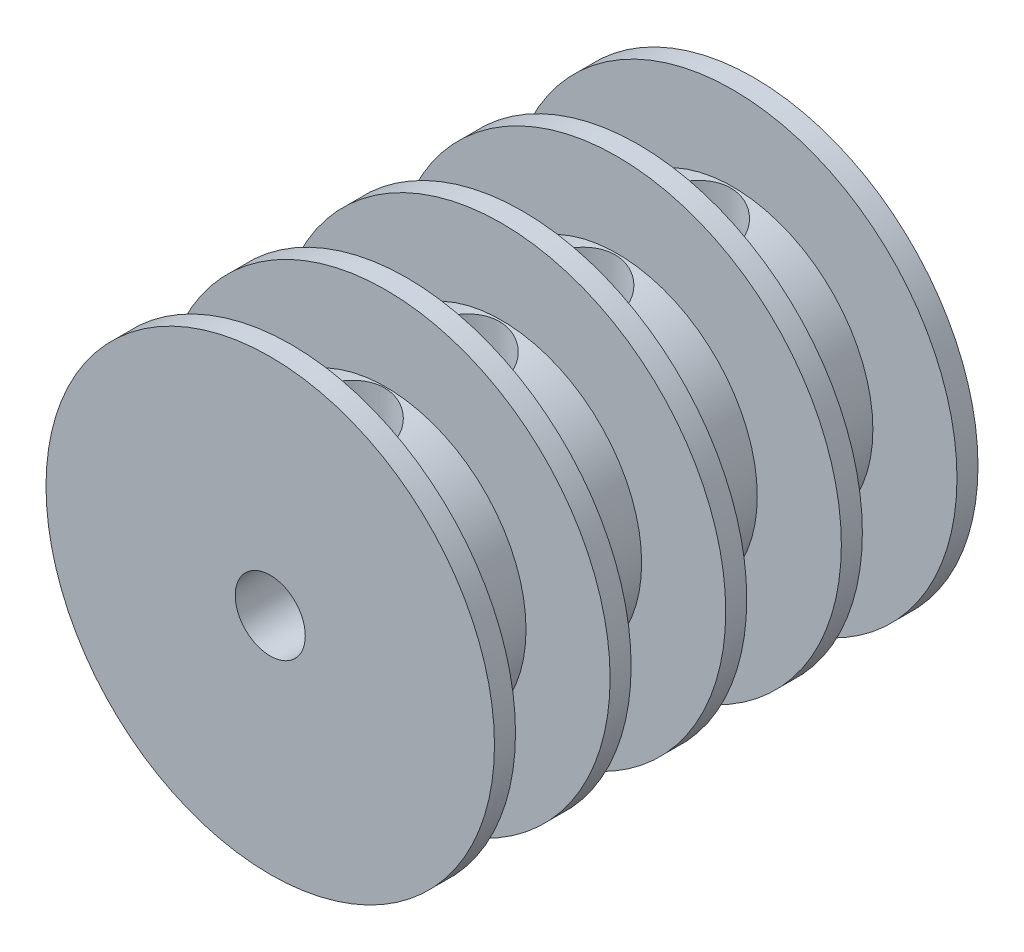
from build123d import *

# Parameters (mm, degrees)
SKETCH_1_R               = 16
EXTRUDE_1_DEPTH          = 1.5
SKETCH_2_R               = 10
EXTRUDE_2_DEPTH          = 15
SKETCH_3_R               = 16
EXTRUDE_3_DEPTH          = 1.5
SKETCH_4_R               = 2.5
CUT_EXTRUDE_1_DEPTH      = 19
SKETCH_11_R              = 16
SKETCH_11_R_2            = 10
EXTRUDE_4_DEPTH          = 0.75
HOLE_WIZARD_M3_2_D       = 2.5
PATTERN_CIRCULAR_2_COUNT = 2
HOLE_WIZARD_M3_3_D       = 2.5
SKETCH_21_R              = 10
EXTRUDE_7_DEPTH          = 15
SKETCH_22_R              = 16
EXTRUDE_8_DEPTH          = 1.5
SKETCH_23_R              = 16
EXTRUDE_9_DEPTH          = 0.75
PATTERN_LINEAR_1_COUNT   = 3
PATTERN_LINEAR_1_PITCH   = 8.25
PATTERN_CIRCULAR_1_COUNT = 2
HOLE_WIZARD_M3_4_D       = 2.5
SKETCH_26_R              = 2.5
CUT_EXTRUDE_2_DEPTH      = 35.5


with BuildPart() as part:
    # 스케치1 → 보스-돌출1 (new body)
    with BuildSketch(Plane.XY):
        Circle(SKETCH_1_R)
    extrude(amount=EXTRUDE_1_DEPTH)

    # 스케치2 → 보스-돌출2 (add)
    with BuildSketch(Plane.XY.offset(1.5)):
        Circle(SKETCH_2_R)
    extrude(amount=EXTRUDE_2_DEPTH)

    # 스케치3 → 보스-돌출3 (add)
    with BuildSketch(Plane.XY.offset(16.5)):
        Circle(SKETCH_3_R)
    extrude(amount=EXTRUDE_3_DEPTH)

    # 스케치4 → 컷-돌출1 (cut, through all)
    with BuildSketch(Plane(origin=(0, 25, 0), x_dir=(-1, 0, 0), z_dir=(0, 0, 1))):
        with Locations((0, 25)):
            Circle(SKETCH_4_R)
    extrude(amount=CUT_EXTRUDE_1_DEPTH, mode=Mode.SUBTRACT)

    # 스케치11 → 보스-돌출4 (add, symmetric)
    with BuildSketch(Plane(origin=(0, 0, 9), x_dir=(-1, 0, 0), z_dir=(0, 0, -1))):
        Circle(SKETCH_11_R)
        Circle(SKETCH_11_R_2, mode=Mode.SUBTRACT)
    extrude(amount=EXTRUDE_4_DEPTH, both=True)

    # 스케치10 → Ø6.5 (6.5) 지름 구멍2 (revolve, cut)
    with BuildSketch(Plane(origin=(0, 16, 4.9), x_dir=(0, 0, 1), z_dir=(1, 0, 0))):
        Polygon((0, 0), (0, 11.452797012), (3.25, 9.5), (3.25, 0), align=None)
    hole_wizard_6_5_6_5_2 = revolve(axis=Axis((0, 22.35, 4.9), (0, -1, 0)), mode=Mode.SUBTRACT)

    # M3 나사 구멍2 (through all)
    with Locations(Plane(origin=(0, 16, 0), x_dir=(1, 0, 0), z_dir=(0, 1, 0))):
        with Locations((0, -4.9)):
            Hole(HOLE_WIZARD_M3_2_D / 2)

    # 스케치13 → Ø6.5 (6.5) 지름 구멍1 (revolve, cut)
    with BuildSketch(Plane(origin=(0, 16, 13.1), x_dir=(0, 0, 1), z_dir=(1, 0, 0))):
        Polygon((0, 0), (0, 11.452797012), (3.25, 9.5), (3.25, 0), align=None)
    hole_wizard_6_5_6_5_1 = revolve(axis=Axis((0, 22.35, 13.1), (0, -1, 0)), mode=Mode.SUBTRACT)

    # 원형 패턴2: Ø6.5 (6.5) 지름 구멍1 ×2 about axis
    pattern_circular_2_axis = Axis((0, 0, 0), (0, 0, 1))
    for i in range(1, PATTERN_CIRCULAR_2_COUNT):
        add(hole_wizard_6_5_6_5_1.rotate(pattern_circular_2_axis, i * 360 / PATTERN_CIRCULAR_2_COUNT), mode=Mode.SUBTRACT)

    # M3 나사 구멍3 (through all)
    with Locations(Plane(origin=(0, 16, 0), x_dir=(1, 0, 0), z_dir=(0, 1, 0))):
        with Locations((0, -13.1)):
            Hole(HOLE_WIZARD_M3_3_D / 2)

    # 스케치21 → 보스-돌출7 (add)
    with BuildSketch(Plane(origin=(0, 0, 0), x_dir=(-1, 0, 0), z_dir=(0, 0, -1))):
        Circle(SKETCH_21_R)
    extrude(amount=EXTRUDE_7_DEPTH)

    # 스케치22 → 보스-돌출8 (add)
    with BuildSketch(Plane(origin=(0, 0, -15), x_dir=(-1, 0, 0), z_dir=(0, 0, -1))):
        Circle(SKETCH_22_R)
    extrude(amount=EXTRUDE_8_DEPTH)

    # 스케치23 → 보스-돌출9 (add, symmetric)
    with BuildSketch(Plane(origin=(0, 0, -7.5), x_dir=(-1, 0, 0), z_dir=(0, 0, -1))):
        Circle(SKETCH_23_R)
    extrude(amount=EXTRUDE_9_DEPTH, both=True)

    # 선형 패턴1: Ø6.5 (6.5) 지름 구멍2 ×3
    with Locations(*[(0, 0, -i * PATTERN_LINEAR_1_PITCH) for i in range(1, PATTERN_LINEAR_1_COUNT)]):
        add(hole_wizard_6_5_6_5_2, mode=Mode.SUBTRACT)

    # 원형 패턴1: Ø6.5 (6.5) 지름 구멍2 ×2 about axis
    pattern_circular_1_axis = Axis((0, 0, 16.5), (0, 0, -1))
    for i in range(1, PATTERN_CIRCULAR_1_COUNT):
        add(hole_wizard_6_5_6_5_2.rotate(pattern_circular_1_axis, i * 360 / PATTERN_CIRCULAR_1_COUNT), mode=Mode.SUBTRACT)

    # 원형 패턴1 copy 1 sketch → 원형 패턴1 copy 1 (revolve, cut)
    with BuildSketch(Plane(origin=(0, -16, -3.35), x_dir=(0, 0, 1), z_dir=(-1, 0, 0))):
        Polygon((0, 0), (0, 11.452797012), (3.25, 9.5), (3.25, 0), align=None)
    revolve(axis=Axis((0, -22.35, -3.35), (0, 1, 0)), mode=Mode.SUBTRACT)

    # 원형 패턴1 copy 2 sketch → 원형 패턴1 copy 2 (revolve, cut)
    with BuildSketch(Plane(origin=(0, -16, -11.6), x_dir=(0, 0, 1), z_dir=(-1, 0, 0))):
        Polygon((0, 0), (0, 11.452797012), (3.25, 9.5), (3.25, 0), align=None)
    revolve(axis=Axis((0, -22.35, -11.6), (0, 1, 0)), mode=Mode.SUBTRACT)

    # M3 나사 구멍4 (through all)
    with Locations(Plane(origin=(0, 16, 0), x_dir=(1, 0, 0), z_dir=(0, 1, 0))):
        with Locations((0, 3.35), (0, 11.6)):
            Hole(HOLE_WIZARD_M3_4_D / 2)

    # 스케치26 → 컷-돌출2 (cut, through all)
    with BuildSketch(Plane.XY.offset(18)):
        Circle(SKETCH_26_R)
    extrude(amount=-CUT_EXTRUDE_2_DEPTH, mode=Mode.SUBTRACT)


solid = part.part
